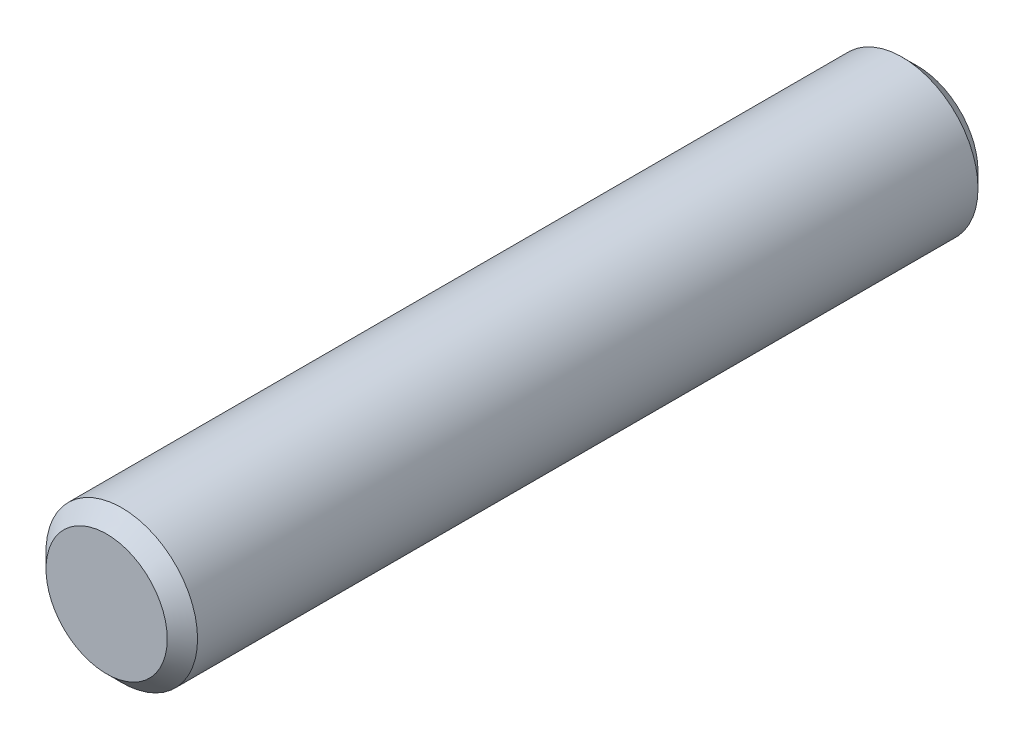
from build123d import *

# Parameters (mm, degrees)
SKETCH3_R           = 7.9375
BOSS_EXTRUDE1_DEPTH = 42.4625
CHAMFER1_SIZE       = 1.5875


with BuildPart() as part:
    # Sketch3 → Boss-Extrude1 (new body, symmetric)
    with BuildSketch(Plane.XY):
        Circle(SKETCH3_R)
    extrude(amount=BOSS_EXTRUDE1_DEPTH, both=True)

    # Chamfer1
    chamfer1_edges = [part.edges().sort_by_distance(p)[0] for p in [
        (-7.9375, 0, -42.4625),
        (-7.9375, 0, 42.4625),
    ]]
    chamfer(chamfer1_edges, length=CHAMFER1_SIZE)


solid = part.part
